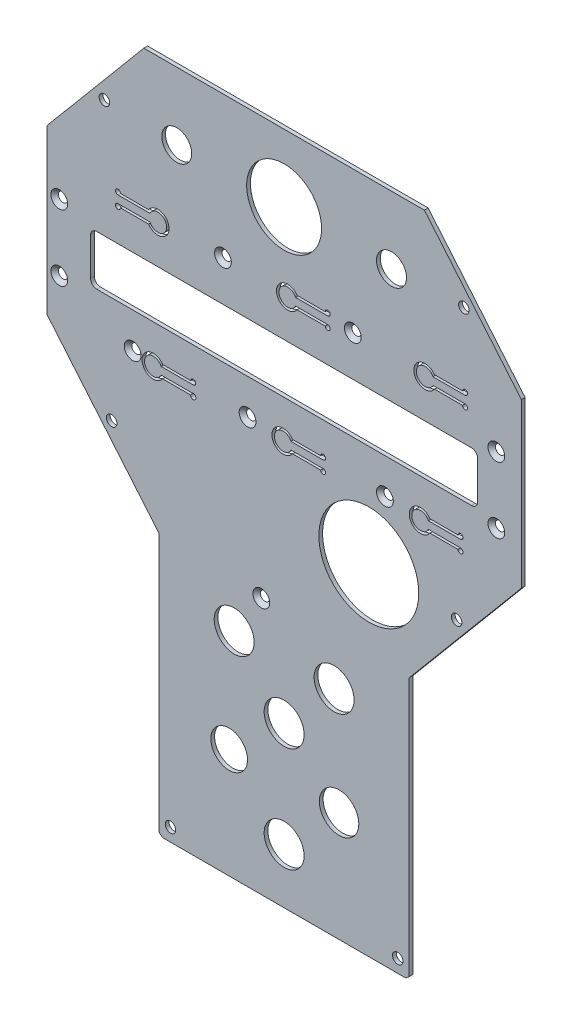
from build123d import *

# Parameters (mm, degrees)
RESSALTO_EXTRUS_O1_DEPTH                      = 1.5
CORTE_EXTRUS_O1_REACH                         = 3.5
ESBO_O2_R                                     = 2.1
CORTE_EXTRUS_O2_REACH                         = 3.5
CORTE_EXTRUS_O3_REACH                         = 3.5
ESBO_O4_R                                     = 20
CORTE_EXTRUS_O4_REACH                         = 3.5
ESBO_O5_R                                     = 8
ESBO_O5_R_2                                   = 7.345398281
ESBO_O5_R_3                                   = 7.894810857
ESBO_O5_R_4                                   = 15
ESBO_O5_R_5                                   = 6
ESCAREADO_PARA_PARAFUSO_ALLEN_SEXTAV_2_COUNT  = 2
ESCAREADO_PARA_PARAFUSO_ALLEN_SEXTAV_2_PITCH  = 26.5
ESCAREADO_PARA_PARAFUSO_ALLEN_SEXTAV_3_COUNT  = 2
ESCAREADO_PARA_PARAFUSO_ALLEN_SEXTAV_3_PITCH  = 47.918783057
ESCAREADO_PARA_PARAFUSO_ALLEN_SEXTAV_4_COUNT  = 2
ESCAREADO_PARA_PARAFUSO_ALLEN_SEXTAV_4_PITCH  = 84.354894452
ESCAREADO_PARA_PARAFUSO_ALLEN_SEXTAV_5_COUNT  = 2
ESCAREADO_PARA_PARAFUSO_ALLEN_SEXTAV_5_PITCH  = 135.769067452
ESCAREADO_PARA_PARAFUSO_ALLEN_SEXTAV_6_COUNT  = 2
ESCAREADO_PARA_PARAFUSO_ALLEN_SEXTAV_6_PITCH  = 176.995056428
ESCAREADO_PARA_PARAFUSO_ALLEN_SEXTAV_7_COUNT  = 2
ESCAREADO_PARA_PARAFUSO_ALLEN_SEXTAV_7_PITCH  = 175
ESCAREADO_PARA_PARAFUSO_ALLEN_SEXTAV_8_COUNT  = 2
ESCAREADO_PARA_PARAFUSO_ALLEN_SEXTAV_8_PITCH  = 118.186850654
ESCAREADO_PARA_PARAFUSO_ALLEN_SEXTAV_9_COUNT  = 2
ESCAREADO_PARA_PARAFUSO_ALLEN_SEXTAV_9_PITCH  = 66.706784875
ESCAREADO_PARA_PARAFUSO_ALLEN_SEXTAV_10_COUNT = 2
ESCAREADO_PARA_PARAFUSO_ALLEN_SEXTAV_10_PITCH = 126.953928461
CORTE_EXTRUS_O5_DEPTH                         = 10


with BuildPart() as part:
    # Esboço1 → Ressalto-extrusão1 (new body)
    with BuildSketch(Plane.XY):
        Polygon((55.321046002, 133.809611411), (-57.006999458, 133.809611411), (-95.842976728, 87.526695978), (-95.842976728, 22.140182404), (-50.842976728, -31.488729263), (-50.842976728, -135.082673958), (-49.522853837, -136.190388589), (47.836900381, -136.190388589), (49.157023272, -135.082673958), (49.157023272, -31.488729263), (94.157023272, 22.140182404), (94.157023272, 87.526695978), align=None)
    extrude(amount=RESSALTO_EXTRUS_O1_DEPTH)

    # Esboço2 → Corte-extrusão1 (cut, up to next)
    with BuildSketch(Plane.XY.offset(1.5), mode=Mode.PRIVATE) as corte_extrus_o1_sk1:
        with Locations((-72.814392548, 107.949888211)):
            Circle(ESBO_O2_R)
    corte_extrus_o1_tool1 = extrude(corte_extrus_o1_sk1.sketch, amount=-CORTE_EXTRUS_O1_REACH, mode=Mode.PRIVATE) & part.part
    add(corte_extrus_o1_tool1.solids().sort_by_distance((-72.814393, 107.949888, 1.5))[0], mode=Mode.SUBTRACT)
    # Esboço2 → Corte-extrusão1 (cut, up to next)
    with BuildSketch(Plane.XY.offset(1.5), mode=Mode.PRIVATE) as corte_extrus_o1_sk2:
        with Locations((-46.342976728, -130.964393909)):
            Circle(ESBO_O2_R)
    corte_extrus_o1_tool2 = extrude(corte_extrus_o1_sk2.sketch, amount=-CORTE_EXTRUS_O1_REACH, mode=Mode.PRIVATE) & part.part
    add(corte_extrus_o1_tool2.solids().sort_by_distance((-46.342977, -130.964394, 1.5))[0], mode=Mode.SUBTRACT)
    # Esboço2 → Corte-extrusão1 (cut, up to next)
    with BuildSketch(Plane.XY.offset(1.5), mode=Mode.PRIVATE) as corte_extrus_o1_sk3:
        with Locations((44.657023272, -130.964393909)):
            Circle(ESBO_O2_R)
    corte_extrus_o1_tool3 = extrude(corte_extrus_o1_sk3.sketch, amount=-CORTE_EXTRUS_O1_REACH, mode=Mode.PRIVATE) & part.part
    add(corte_extrus_o1_tool3.solids().sort_by_distance((44.657023, -130.964394, 1.5))[0], mode=Mode.SUBTRACT)
    # Esboço2 → Corte-extrusão1 (cut, up to next)
    with BuildSketch(Plane.XY.offset(1.5), mode=Mode.PRIVATE) as corte_extrus_o1_sk4:
        with Locations((71.128439092, 107.949888211)):
            Circle(ESBO_O2_R)
    corte_extrus_o1_tool4 = extrude(corte_extrus_o1_sk4.sketch, amount=-CORTE_EXTRUS_O1_REACH, mode=Mode.PRIVATE) & part.part
    add(corte_extrus_o1_tool4.solids().sort_by_distance((71.128439, 107.949888, 1.5))[0], mode=Mode.SUBTRACT)
    # Esboço2 → Corte-extrusão1 (cut, up to next)
    with BuildSketch(Plane.XY.offset(1.5), mode=Mode.PRIVATE) as corte_extrus_o1_sk5:
        with Locations((-69.895776734, -1.781729186)):
            Circle(ESBO_O2_R)
    corte_extrus_o1_tool5 = extrude(corte_extrus_o1_sk5.sketch, amount=-CORTE_EXTRUS_O1_REACH, mode=Mode.PRIVATE) & part.part
    add(corte_extrus_o1_tool5.solids().sort_by_distance((-69.895777, -1.781729, 1.5))[0], mode=Mode.SUBTRACT)
    # Esboço2 → Corte-extrusão1 (cut, up to next)
    with BuildSketch(Plane.XY.offset(1.5), mode=Mode.PRIVATE) as corte_extrus_o1_sk6:
        with Locations((68.209823278, -1.781729186)):
            Circle(ESBO_O2_R)
    corte_extrus_o1_tool6 = extrude(corte_extrus_o1_sk6.sketch, amount=-CORTE_EXTRUS_O1_REACH, mode=Mode.PRIVATE) & part.part
    add(corte_extrus_o1_tool6.solids().sort_by_distance((68.209823, -1.781729, 1.5))[0], mode=Mode.SUBTRACT)

    # Esboço3 → Corte-extrusão2 (cut, up to next)
    with BuildSketch(Plane.XY.offset(1.5), mode=Mode.PRIVATE) as corte_extrus_o2_sk1:
        with BuildLine():
            Line((-75.842976728, 40.809611411), (74.157023272, 40.809611411))
            ThreePointArc((74.157023272, 40.809611411), (75.924790225, 41.541844458), (76.657023272, 43.309611411))
            Line((76.657023272, 43.309611411), (76.657023272, 58.309611411))
            ThreePointArc((76.657023272, 58.309611411), (75.924790225, 60.077378364), (74.157023272, 60.809611411))
            Line((74.157023272, 60.809611411), (-75.842976728, 60.809611411))
            ThreePointArc((-75.842976728, 60.809611411), (-77.610743681, 60.077378364), (-78.342976728, 58.309611411))
            Line((-78.342976728, 58.309611411), (-78.342976728, 43.309611411))
            ThreePointArc((-78.342976728, 43.309611411), (-77.610743681, 41.541844458), (-75.842976728, 40.809611411))
        make_face()
    corte_extrus_o2_tool1 = extrude(corte_extrus_o2_sk1.sketch, amount=-CORTE_EXTRUS_O2_REACH, mode=Mode.PRIVATE) & part.part
    add(corte_extrus_o2_tool1.solids().sort_by_distance((-0.842977, 50.809611, 1.5))[0], mode=Mode.SUBTRACT)

    # Esboço4 → Corte-extrusão3 (cut, up to next)
    with BuildSketch(Plane.XY.offset(1.5), mode=Mode.PRIVATE) as corte_extrus_o3_sk1:
        with Locations((33.056325833, -0.190388589)):
            Circle(ESBO_O4_R)
    corte_extrus_o3_tool1 = extrude(corte_extrus_o3_sk1.sketch, amount=-CORTE_EXTRUS_O3_REACH, mode=Mode.PRIVATE) & part.part
    add(corte_extrus_o3_tool1.solids().sort_by_distance((33.056326, -0.190389, 1.5))[0], mode=Mode.SUBTRACT)

    # Esboço5 → Corte-extrusão4 (cut, up to next)
    with BuildSketch(Plane.XY.offset(1.5), mode=Mode.PRIVATE) as corte_extrus_o4_sk1:
        with Locations((-0.842976728, -114.190388589)):
            Circle(ESBO_O5_R)
    corte_extrus_o4_tool1 = extrude(corte_extrus_o4_sk1.sketch, amount=-CORTE_EXTRUS_O4_REACH, mode=Mode.PRIVATE) & part.part
    add(corte_extrus_o4_tool1.solids().sort_by_distance((-0.842977, -114.190389, 1.5))[0], mode=Mode.SUBTRACT)
    # Esboço5 → Corte-extrusão4 (cut, up to next)
    with BuildSketch(Plane.XY.offset(1.5), mode=Mode.PRIVATE) as corte_extrus_o4_sk2:
        with Locations((-0.842976728, -72.190388589)):
            Circle(ESBO_O5_R)
    corte_extrus_o4_tool2 = extrude(corte_extrus_o4_sk2.sketch, amount=-CORTE_EXTRUS_O4_REACH, mode=Mode.PRIVATE) & part.part
    add(corte_extrus_o4_tool2.solids().sort_by_distance((-0.842977, -72.190389, 1.5))[0], mode=Mode.SUBTRACT)
    # Esboço5 → Corte-extrusão4 (cut, up to next)
    with BuildSketch(Plane.XY.offset(1.5), mode=Mode.PRIVATE) as corte_extrus_o4_sk3:
        with Locations((-22.842976728, -92.190388589)):
            Circle(ESBO_O5_R_2)
    corte_extrus_o4_tool3 = extrude(corte_extrus_o4_sk3.sketch, amount=-CORTE_EXTRUS_O4_REACH, mode=Mode.PRIVATE) & part.part
    add(corte_extrus_o4_tool3.solids().sort_by_distance((-22.842977, -92.190389, 1.5))[0], mode=Mode.SUBTRACT)
    # Esboço5 → Corte-extrusão4 (cut, up to next)
    with BuildSketch(Plane.XY.offset(1.5), mode=Mode.PRIVATE) as corte_extrus_o4_sk4:
        with Locations((21.157023272, -92.190388589)):
            Circle(ESBO_O5_R_3)
    corte_extrus_o4_tool4 = extrude(corte_extrus_o4_sk4.sketch, amount=-CORTE_EXTRUS_O4_REACH, mode=Mode.PRIVATE) & part.part
    add(corte_extrus_o4_tool4.solids().sort_by_distance((21.157023, -92.190389, 1.5))[0], mode=Mode.SUBTRACT)
    # Esboço5 → Corte-extrusão4 (cut, up to next)
    with BuildSketch(Plane.XY.offset(1.5), mode=Mode.PRIVATE) as corte_extrus_o4_sk5:
        with Locations((-20.842976728, -50.190388589)):
            Circle(ESBO_O5_R)
    corte_extrus_o4_tool5 = extrude(corte_extrus_o4_sk5.sketch, amount=-CORTE_EXTRUS_O4_REACH, mode=Mode.PRIVATE) & part.part
    add(corte_extrus_o4_tool5.solids().sort_by_distance((-20.842977, -50.190389, 1.5))[0], mode=Mode.SUBTRACT)
    # Esboço5 → Corte-extrusão4 (cut, up to next)
    with BuildSketch(Plane.XY.offset(1.5), mode=Mode.PRIVATE) as corte_extrus_o4_sk6:
        with Locations((19.157023272, -50.190388589)):
            Circle(ESBO_O5_R)
    corte_extrus_o4_tool6 = extrude(corte_extrus_o4_sk6.sketch, amount=-CORTE_EXTRUS_O4_REACH, mode=Mode.PRIVATE) & part.part
    add(corte_extrus_o4_tool6.solids().sort_by_distance((19.157023, -50.190389, 1.5))[0], mode=Mode.SUBTRACT)
    # Esboço5 → Corte-extrusão4 (cut, up to next)
    with BuildSketch(Plane.XY.offset(1.5), mode=Mode.PRIVATE) as corte_extrus_o4_sk7:
        with Locations((-0.842976728, 106.809611411)):
            Circle(ESBO_O5_R_4)
    corte_extrus_o4_tool7 = extrude(corte_extrus_o4_sk7.sketch, amount=-CORTE_EXTRUS_O4_REACH, mode=Mode.PRIVATE) & part.part
    add(corte_extrus_o4_tool7.solids().sort_by_distance((-0.842977, 106.809611, 1.5))[0], mode=Mode.SUBTRACT)
    # Esboço5 → Corte-extrusão4 (cut, up to next)
    with BuildSketch(Plane.XY.offset(1.5), mode=Mode.PRIVATE) as corte_extrus_o4_sk8:
        with Locations((-43.842976728, 106.809611411)):
            Circle(ESBO_O5_R_5)
    corte_extrus_o4_tool8 = extrude(corte_extrus_o4_sk8.sketch, amount=-CORTE_EXTRUS_O4_REACH, mode=Mode.PRIVATE) & part.part
    add(corte_extrus_o4_tool8.solids().sort_by_distance((-43.842977, 106.809611, 1.5))[0], mode=Mode.SUBTRACT)
    # Esboço5 → Corte-extrusão4 (cut, up to next)
    with BuildSketch(Plane.XY.offset(1.5), mode=Mode.PRIVATE) as corte_extrus_o4_sk9:
        with Locations((42.157023272, 106.809611411)):
            Circle(ESBO_O5_R_5)
    corte_extrus_o4_tool9 = extrude(corte_extrus_o4_sk9.sketch, amount=-CORTE_EXTRUS_O4_REACH, mode=Mode.PRIVATE) & part.part
    add(corte_extrus_o4_tool9.solids().sort_by_distance((42.157023, 106.809611, 1.5))[0], mode=Mode.SUBTRACT)

    # Esboço11 → Escareado para parafuso Allen sextavado escareado de M32 (revolve, cut)
    with BuildSketch(Plane(origin=(-90.868976728, 64.471011411, 1.5), x_dir=(0, -1, 0), z_dir=(1, 0, 0))):
        Polygon((0, 0), (0, 1.5), (1.7, 1.5), (1.7, 1.66), (3.36, 0), align=None)
    escareado_para_parafuso_allen_sextavado = revolve(axis=Axis((-90.868976728, 64.471011411, 7.85), (0, 0, -1)), mode=Mode.SUBTRACT)

    # Escareado para parafuso Allen sextav 2: Escareado para parafuso Allen sextavado escareado de M32 ×2
    with Locations(*[(0, -i * ESCAREADO_PARA_PARAFUSO_ALLEN_SEXTAV_2_PITCH, 0) for i in range(1, ESCAREADO_PARA_PARAFUSO_ALLEN_SEXTAV_2_COUNT)]):
        add(escareado_para_parafuso_allen_sextavado, mode=Mode.SUBTRACT)

    # Escareado para parafuso Allen sextav 3: Escareado para parafuso Allen sextavado escareado de M32 ×2
    with Locations(*[Vector(0.613251976, -0.789887343, 0) * (i * ESCAREADO_PARA_PARAFUSO_ALLEN_SEXTAV_3_PITCH) for i in range(1, ESCAREADO_PARA_PARAFUSO_ALLEN_SEXTAV_3_COUNT)]):
        add(escareado_para_parafuso_allen_sextavado, mode=Mode.SUBTRACT)

    # Escareado para parafuso Allen sextav 4: Escareado para parafuso Allen sextavado escareado de M32 ×2
    with Locations(*[Vector(0.893680068, -0.448704731, 0) * (i * ESCAREADO_PARA_PARAFUSO_ALLEN_SEXTAV_4_PITCH) for i in range(1, ESCAREADO_PARA_PARAFUSO_ALLEN_SEXTAV_4_COUNT)]):
        add(escareado_para_parafuso_allen_sextavado, mode=Mode.SUBTRACT)

    # Escareado para parafuso Allen sextav 5: Escareado para parafuso Allen sextavado escareado de M32 ×2
    with Locations(*[Vector(0.960353411, -0.278785447, 0) * (i * ESCAREADO_PARA_PARAFUSO_ALLEN_SEXTAV_5_PITCH) for i in range(1, ESCAREADO_PARA_PARAFUSO_ALLEN_SEXTAV_5_COUNT)]):
        add(escareado_para_parafuso_allen_sextavado, mode=Mode.SUBTRACT)

    # Escareado para parafuso Allen sextav 6: Escareado para parafuso Allen sextavado escareado de M32 ×2
    with Locations(*[Vector(0.98872818, -0.149721696, 0) * (i * ESCAREADO_PARA_PARAFUSO_ALLEN_SEXTAV_6_PITCH) for i in range(1, ESCAREADO_PARA_PARAFUSO_ALLEN_SEXTAV_6_COUNT)]):
        add(escareado_para_parafuso_allen_sextavado, mode=Mode.SUBTRACT)

    # Escareado para parafuso Allen sextav 7: Escareado para parafuso Allen sextavado escareado de M32 ×2
    with Locations(*[(i * ESCAREADO_PARA_PARAFUSO_ALLEN_SEXTAV_7_PITCH, 0, 0) for i in range(1, ESCAREADO_PARA_PARAFUSO_ALLEN_SEXTAV_7_COUNT)]):
        add(escareado_para_parafuso_allen_sextavado, mode=Mode.SUBTRACT)

    # Escareado para parafuso Allen sextav 8: Escareado para parafuso Allen sextavado escareado de M32 ×2
    with Locations(*[Vector(0.994378526, 0.105883648, 0) * (i * ESCAREADO_PARA_PARAFUSO_ALLEN_SEXTAV_8_PITCH) for i in range(1, ESCAREADO_PARA_PARAFUSO_ALLEN_SEXTAV_8_COUNT)]):
        add(escareado_para_parafuso_allen_sextavado, mode=Mode.SUBTRACT)

    # Escareado para parafuso Allen sextav 9: Escareado para parafuso Allen sextavado escareado de M32 ×2
    with Locations(*[Vector(0.982245904, 0.187597932, 0) * (i * ESCAREADO_PARA_PARAFUSO_ALLEN_SEXTAV_9_PITCH) for i in range(1, ESCAREADO_PARA_PARAFUSO_ALLEN_SEXTAV_9_COUNT)]):
        add(escareado_para_parafuso_allen_sextavado, mode=Mode.SUBTRACT)

    # Escareado para parafuso Allen sextav 10: Escareado para parafuso Allen sextavado escareado de M32 ×2
    with Locations(*[Vector(0.637131028, -0.770755508, 0) * (i * ESCAREADO_PARA_PARAFUSO_ALLEN_SEXTAV_10_PITCH) for i in range(1, ESCAREADO_PARA_PARAFUSO_ALLEN_SEXTAV_10_COUNT)]):
        add(escareado_para_parafuso_allen_sextavado, mode=Mode.SUBTRACT)

    # Esboço12 → Corte-extrusão5 (cut)
    with BuildSketch(Plane.XY.offset(1.5)):
        with BuildLine():
            Line((56.929587991, 26.909611411), (69.767310331, 26.909611411))
            ThreePointArc((69.767310331, 26.909611411), (70.474417112, 28.616718193), (68.767310331, 27.909611411))
            Line((68.767310331, 27.909611411), (57.508967718, 27.909611411))
            ThreePointArc((57.508967718, 27.909611411), (49.267310331, 25.409611411), (57.508967718, 22.909611411))
            Line((57.508967718, 22.909611411), (68.767310331, 22.909611411))
            ThreePointArc((68.767310331, 22.909611411), (70.474417112, 22.20250463), (69.767310331, 23.909611411))
            Line((69.767310331, 23.909611411), (56.929587991, 23.909611411))
            ThreePointArc((56.929587991, 23.909611411), (50.267310331, 25.409611411), (56.929587991, 26.909611411))
        make_face()
        with BuildLine():
            Line((1.929587991, 26.909611411), (14.767310331, 26.909611411))
            ThreePointArc((14.767310331, 26.909611411), (15.474417112, 28.616718193), (13.767310331, 27.909611411))
            Line((13.767310331, 27.909611411), (2.508967718, 27.909611411))
            ThreePointArc((2.508967718, 27.909611411), (-5.732689669, 25.409611411), (2.508967718, 22.909611411))
            Line((2.508967718, 22.909611411), (13.767310331, 22.909611411))
            ThreePointArc((13.767310331, 22.909611411), (15.474417112, 22.20250463), (14.767310331, 23.909611411))
            Line((14.767310331, 23.909611411), (1.929587991, 23.909611411))
            ThreePointArc((1.929587991, 23.909611411), (-4.732689669, 25.409611411), (1.929587991, 26.909611411))
        make_face()
        with BuildLine():
            Line((-50.070412009, 26.909611411), (-37.232689669, 26.909611411))
            ThreePointArc((-37.232689669, 26.909611411), (-36.525582888, 28.616718193), (-38.232689669, 27.909611411))
            Line((-38.232689669, 27.909611411), (-49.491032282, 27.909611411))
            ThreePointArc((-49.491032282, 27.909611411), (-57.732689669, 25.409611411), (-49.491032282, 22.909611411))
            Line((-49.491032282, 22.909611411), (-38.313138828, 22.909611411))
            ThreePointArc((-38.313138828, 22.909611411), (-36.335641136, 22.307386939), (-37.641798927, 23.909611411))
            Line((-37.641798927, 23.909611411), (-50.070412009, 23.909611411))
            ThreePointArc((-50.070412009, 23.909611411), (-56.732689669, 25.409611411), (-50.070412009, 26.909611411))
        make_face()
        with BuildLine():
            Line((3.769300932, 77.759611411), (16.607023272, 77.759611411))
            ThreePointArc((16.607023272, 77.759611411), (17.314130053, 79.466718193), (15.607023272, 78.759611411))
            Line((15.607023272, 78.759611411), (4.348680659, 78.759611411))
            ThreePointArc((4.348680659, 78.759611411), (-3.892976728, 76.259611411), (4.348680659, 73.759611411))
            Line((4.348680659, 73.759611411), (15.607023272, 73.759611411))
            ThreePointArc((15.607023272, 73.759611411), (17.314130053, 73.05250463), (16.607023272, 74.759611411))
            Line((16.607023272, 74.759611411), (3.769300932, 74.759611411))
            ThreePointArc((3.769300932, 74.759611411), (-2.892976728, 76.259611411), (3.769300932, 77.759611411))
        make_face()
        with BuildLine():
            Line((58.769300932, 77.759611411), (71.607023272, 77.759611411))
            ThreePointArc((71.607023272, 77.759611411), (72.314130053, 79.466718193), (70.607023272, 78.759611411))
            Line((70.607023272, 78.759611411), (59.348680659, 78.759611411))
            ThreePointArc((59.348680659, 78.759611411), (51.107023272, 76.259611411), (59.348680659, 73.759611411))
            Line((59.348680659, 73.759611411), (70.607023272, 73.759611411))
            ThreePointArc((70.607023272, 73.759611411), (72.314130053, 73.05250463), (71.607023272, 74.759611411))
            Line((71.607023272, 74.759611411), (58.769300932, 74.759611411))
            ThreePointArc((58.769300932, 74.759611411), (52.107023272, 76.259611411), (58.769300932, 77.759611411))
        make_face()
        with BuildLine():
            Line((-54.555254388, 77.759611411), (-67.392976728, 77.759611411))
            ThreePointArc((-67.392976728, 77.759611411), (-68.100083509, 79.466718193), (-66.392976728, 78.759611411))
            Line((-66.392976728, 78.759611411), (-55.134634115, 78.759611411))
            ThreePointArc((-55.134634115, 78.759611411), (-46.892976728, 76.259611411), (-55.134634115, 73.759611411))
            Line((-55.134634115, 73.759611411), (-66.392976728, 73.759611411))
            ThreePointArc((-66.392976728, 73.759611411), (-68.100083509, 73.05250463), (-67.392976728, 74.759611411))
            Line((-67.392976728, 74.759611411), (-54.555254388, 74.759611411))
            ThreePointArc((-54.555254388, 74.759611411), (-47.892976728, 76.259611411), (-54.555254388, 77.759611411))
        make_face()
    extrude(amount=-CORTE_EXTRUS_O5_DEPTH, mode=Mode.SUBTRACT)


solid = part.part
